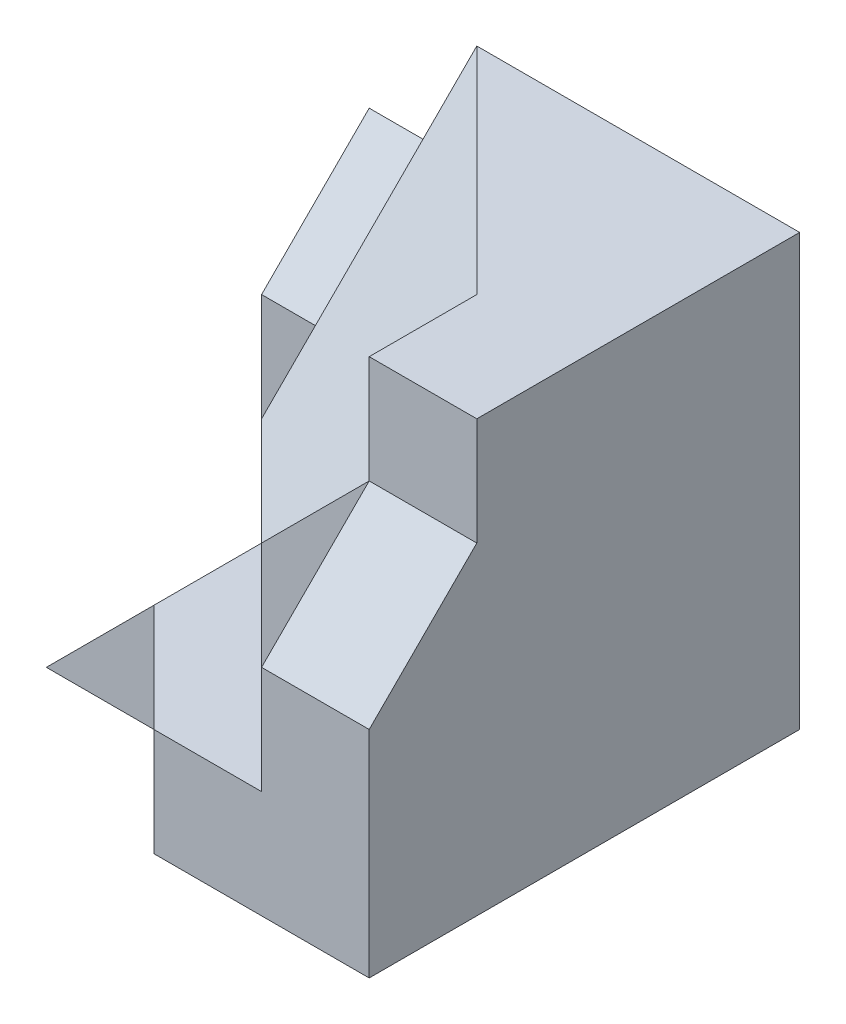
from build123d import *

# Parameters (mm, degrees)
BOSS_EXTRUDE1_DEPTH = 20
SKETCH2_W           = 5
SKETCH2_H           = 15
BOSS_EXTRUDE3_DEPTH = 5
CUT_EXTRUDE2_DEPTH  = 5
BOSS_EXTRUDE4_DEPTH = 20
CUT_EXTRUDE3_DEPTH  = 37
BOSS_EXTRUDE5_DEPTH = 5
SKETCH7_W           = 5
SKETCH7_H           = 5
BOSS_EXTRUDE6_DEPTH = 10
CUT_EXTRUDE4_DEPTH  = 10
BOSS_EXTRUDE7_DEPTH = 5


with BuildPart() as part:
    # Sketch1 → Boss-Extrude1 (new body)
    with BuildSketch(Plane(origin=(0, 0, 0), x_dir=(1, 0, 0), z_dir=(0, 1, 0))):
        Polygon((-15, 0), (0, 0), (0, -15), (-5, -15), (-5, -10), align=None)
    extrude(amount=BOSS_EXTRUDE1_DEPTH)

    # Sketch2 → Boss-Extrude3 (add)
    with BuildSketch(Plane.XY.offset(15)):
        with Locations((-2.5, 7.5)):
            Rectangle(SKETCH2_W, SKETCH2_H)
    extrude(amount=BOSS_EXTRUDE3_DEPTH)

    # Sketch4 → Cut-Extrude2 (cut)
    with BuildSketch(Plane.ZY.offset(5)):
        Polygon((15, 15), (20, 10), (20, 15), align=None)
    extrude(amount=-CUT_EXTRUDE2_DEPTH, mode=Mode.SUBTRACT)

    # Sketch5 → Boss-Extrude4 (add)
    with BuildSketch(Plane(origin=(0, 0, 0), x_dir=(-1, 0, 0), z_dir=(0, -1, 0))):
        Polygon((15, 0), (15, -10), (10, -15), (5, -15), (5, -10), align=None)
    extrude(amount=-BOSS_EXTRUDE4_DEPTH)

    # 3DSketch1 → Cut-Extrude3 (cut, along a direction that is not the sketch's normal)
    with BuildSketch(Plane(origin=(-15, 20, 0), x_dir=(0.5345224838248489, -0.26726124191242445, 0.8017837257372732), z_dir=(0.5773502691896253, -0.5773502691896264, -0.5773502691896257))):
        Polygon((0, 0), (13.363062096, -4.629100499), (18.708286934, 0), (17.371980724, 6.943650748), (10.690449676, 9.258200998), align=None)
    extrude(amount=-CUT_EXTRUDE3_DEPTH, dir=(0, 0, -1), mode=Mode.SUBTRACT)

    # Sketch6 → Boss-Extrude5 (add)
    with BuildSketch(Plane.ZY.offset(15)):
        Polygon((0, 0), (0, 15), (5, 10), (5, 0), align=None)
    extrude(amount=BOSS_EXTRUDE5_DEPTH)

    # Sketch7 → Boss-Extrude6 (add)
    with BuildSketch(Plane.XY.offset(5)):
        with Locations((-17.5, 2.5)):
            Rectangle(SKETCH7_W, SKETCH7_H)
    extrude(amount=BOSS_EXTRUDE6_DEPTH)

    # Sketch8 → Cut-Extrude4 (cut)
    with BuildSketch(Plane.XY.offset(15)):
        Polygon((-20, 0), (-15, 5), (-20, 5), align=None)
    extrude(amount=-CUT_EXTRUDE4_DEPTH, mode=Mode.SUBTRACT)

    # Sketch9 → Boss-Extrude7 (add)
    with BuildSketch(Plane(origin=(0, 0, 0), x_dir=(-1, 0, 0), z_dir=(0, -1, 0))):
        Polygon((15, -15), (15, -10), (10, -15), (5, -15), (5, -20), (10, -20), align=None)
    extrude(amount=-BOSS_EXTRUDE7_DEPTH)


solid = part.part
